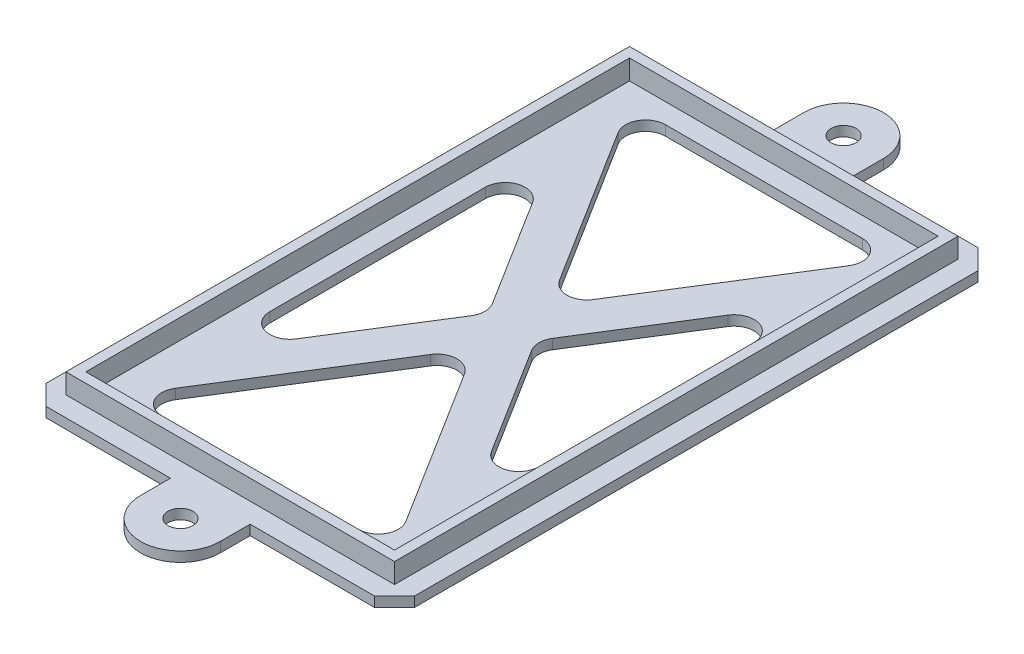
from build123d import *

# Parameters (mm, degrees)
SKETCH1_W           = 41.91
SKETCH1_H           = 71.882
SKETCH1_W_2         = 39.37
SKETCH1_H_2         = 69.342
BOSS_EXTRUDE4_DEPTH = 2.54
SKETCH5_W           = 46.99
SKETCH5_H           = 76.962
BOSS_EXTRUDE5_DEPTH = 1.27
CHAMFER4_SIZE       = 2.54
CUT_EXTRUDE1_DEPTH  = 2.54
FILLET1_R           = 2.54
SKETCH7_R           = 1.5875
BOSS_EXTRUDE6_DEPTH = 1.27


with BuildPart() as part:
    # Sketch1 → Boss-Extrude4 (new body)
    with BuildSketch(Plane(origin=(0, 0, 0), x_dir=(1, 0, 0), z_dir=(0, 1, 0))):
        with Locations((-19.685, -34.671)):
            Rectangle(SKETCH1_W, SKETCH1_H)
        with Locations((-19.685, -34.671)):
            Rectangle(SKETCH1_W_2, SKETCH1_H_2, mode=Mode.SUBTRACT)
    extrude(amount=BOSS_EXTRUDE4_DEPTH)

    # Sketch5 → Boss-Extrude5 (add)
    with BuildSketch(Plane.XZ):
        with Locations((-19.685, 34.671)):
            Rectangle(SKETCH5_W, SKETCH5_H)
    extrude(amount=BOSS_EXTRUDE5_DEPTH)

    # Chamfer4
    chamfer4_edges = [part.edges().sort_by_distance(p)[0] for p in [
        (-43.18, -0.635, 73.152),
        (-43.18, -0.635, -3.81),
        (3.81, -0.635, -3.81),
        (3.81, -0.635, 73.152),
    ]]
    chamfer(chamfer4_edges, length=CHAMFER4_SIZE)

    # Sketch6 → Cut-Extrude1 (cut)
    with BuildSketch(Plane(origin=(0, 0, 0), x_dir=(1, 0, 0), z_dir=(0, 1, 0))):
        Polygon((-36.83, -2.54), (-2.54, -2.54), (-19.685, -29.888964801), align=None)
        Polygon((-36.83, -12.104070398), (-36.83, -57.237929602), (-22.68284632, -34.671), align=None)
        Polygon((-36.83, -66.802), (-2.54, -66.802), (-19.685, -39.453035199), align=None)
        Polygon((-2.54, -12.104070398), (-2.54, -57.237929602), (-16.68715368, -34.671), align=None)
    extrude(amount=-CUT_EXTRUDE1_DEPTH, mode=Mode.SUBTRACT)

    # Fillet1
    fillet1_edges = [part.edges().sort_by_distance(p)[0] for p in [
        (-2.54, -0.635, 2.54),
        (-19.685, -0.635, 29.888964801),
        (-36.83, -0.635, 2.54),
        (-36.83, -0.635, 66.802),
        (-19.685, -0.635, 39.453035199),
        (-2.54, -0.635, 66.802),
        (-22.68284632, -0.635, 34.671),
        (-36.83, -0.635, 57.237929602),
        (-36.83, -0.635, 12.104070398),
        (-16.68715368, -0.635, 34.671),
        (-2.54, -0.635, 12.104070398),
        (-2.54, -0.635, 57.237929602),
    ]]
    fillet(fillet1_edges, radius=FILLET1_R)

    # Sketch7 → Boss-Extrude6 (add)
    with BuildSketch(Plane(origin=(0, 0, 0), x_dir=(1, 0, 0), z_dir=(0, 1, 0))):
        with BuildLine():
            Line((-14.605, 7.62), (-14.605, 3.81))
            Line((-14.605, 3.81), (-24.765, 3.81))
            Line((-24.765, 3.81), (-24.765, 7.62))
            ThreePointArc((-24.765, 7.62), (-19.685, 12.7), (-14.605, 7.62))
        make_face()
        with Locations((-19.685, 7.62)):
            Circle(SKETCH7_R, mode=Mode.SUBTRACT)
        with BuildLine():
            Line((-24.765, -73.152), (-24.765, -76.962))
            ThreePointArc((-24.765, -76.962), (-19.685, -82.042), (-14.605, -76.962))
            Line((-14.605, -76.962), (-14.605, -73.152))
            Line((-14.605, -73.152), (-24.765, -73.152))
        make_face()
        with Locations((-19.685, -76.962)):
            Circle(SKETCH7_R, mode=Mode.SUBTRACT)
    extrude(amount=-BOSS_EXTRUDE6_DEPTH)


solid = part.part
